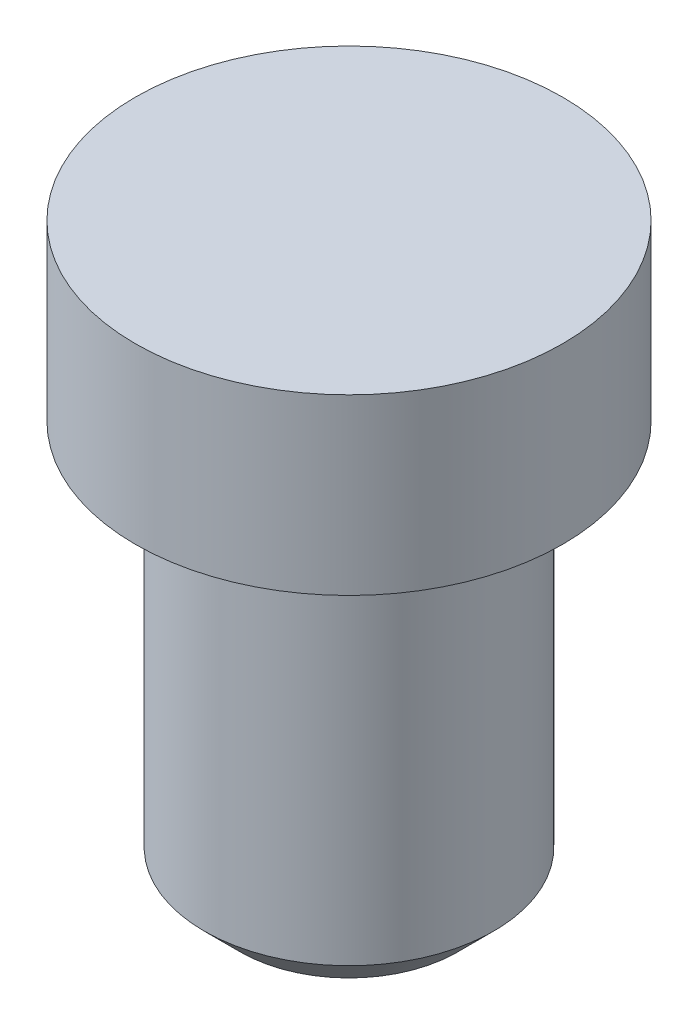
from build123d import *

# Parameters (mm, degrees)
CHAFL_N1_SIZE = 0.5


with BuildPart() as part:
    # Croquis1 → Revolución1 (revolve)
    with BuildSketch(Plane.XY):
        Polygon((0, 0), (2.95, 0), (2.95, -2.4), (2, -2.4), (2, -8), (0, -8), align=None)
    revolve(axis=Axis((0, 0, 0), (0, -1, 0)))

    # Chaflán1
    chafl_n1_edges = [part.edges().sort_by_distance(p)[0] for p in [
        (-2, -8, 0),
    ]]
    chamfer(chafl_n1_edges, length=CHAFL_N1_SIZE)


solid = part.part
